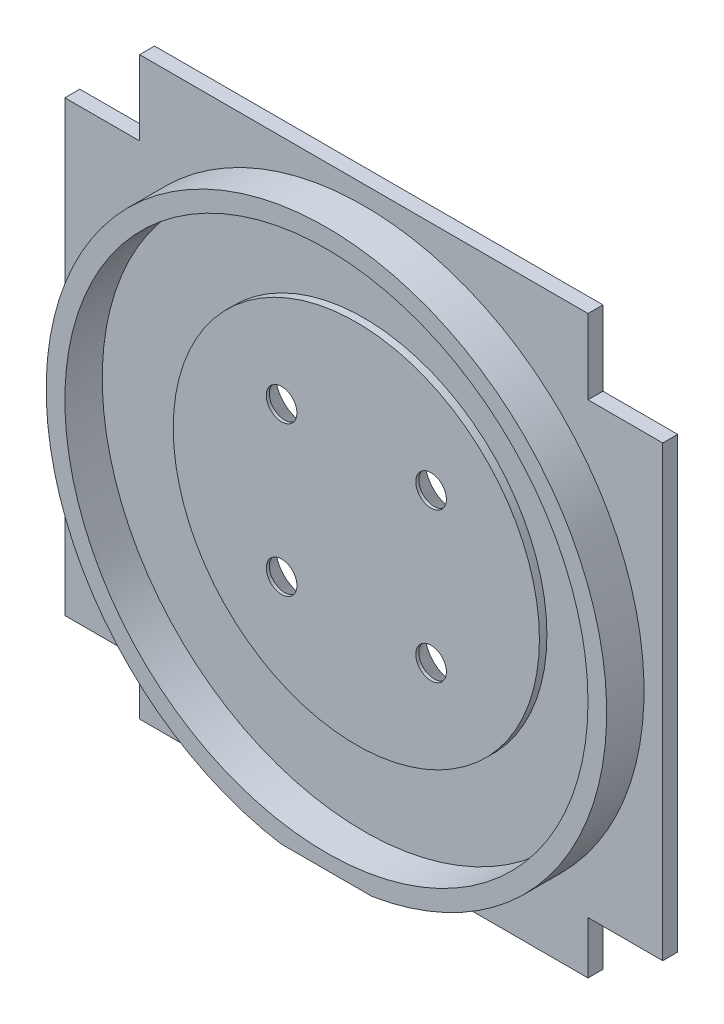
from build123d import *

# Parameters (mm, degrees)
ESQUISSE1_W             = 80
ESQUISSE1_H             = 80
BOSS_EXTRU_1_DEPTH      = 2
ESQUISSE2_R             = 24.5
BOSS_EXTRU_2_DEPTH      = 1
ESQUISSE3_R             = 2.05
ENL_V_MAT_EXTRU_1_DEPTH = 4
CHANFREIN1_SIZE         = 1.75
CHANFREIN1_SIZE2        = 2.594481695
ESQUISSE4_R             = 37.5
ESQUISSE4_R_2           = 35
BOSS_EXTRU_3_DEPTH      = 5
ESQUISSE5_W             = 80
ESQUISSE5_H             = 3
ENL_V_MAT_EXTRU_2_DEPTH = 8
ESQUISSE6_W             = 10
ESQUISSE6_H             = 10
ESQUISSE6_H_2           = 7
ENL_V_MAT_EXTRU_3_DEPTH = 8


with BuildPart() as part:
    # Esquisse1 → Boss.-Extru.1 (new body)
    with BuildSketch(Plane.XY):
        with Locations((40, 40)):
            Rectangle(ESQUISSE1_W, ESQUISSE1_H)
    extrude(amount=BOSS_EXTRU_1_DEPTH)

    # Esquisse2 → Boss.-Extru.2 (add)
    with BuildSketch(Plane.XY.offset(2)):
        with Locations((40, 40)):
            Circle(ESQUISSE2_R)
    extrude(amount=BOSS_EXTRU_2_DEPTH)

    # Esquisse3 → Enlèv. mat.-Extru.1 (cut, through all)
    with BuildSketch(Plane(origin=(0, 0, 0), x_dir=(-1, 0, 0), z_dir=(0, 0, -1))):
        with Locations((-50, 50)):
            Circle(ESQUISSE3_R)
        with Locations((-50, 30)):
            Circle(ESQUISSE3_R)
        with Locations((-30, 30)):
            Circle(ESQUISSE3_R)
        with Locations((-30, 50)):
            Circle(ESQUISSE3_R)
    extrude(amount=-ENL_V_MAT_EXTRU_1_DEPTH, mode=Mode.SUBTRACT)

    # Chanfrein1
    chanfrein1_edges = [part.edges().sort_by_distance(p)[0] for p in [
        (52.05, 50, 0),
        (52.05, 30, 0),
        (32.05, 30, 0),
        (32.05, 50, 0),
    ]]
    chanfrein1_side = [part.faces().sort_by_distance(p)[0] for p in [
        (40, 40, 0),
    ]]
    chamfer(chanfrein1_edges, length=CHANFREIN1_SIZE, length2=CHANFREIN1_SIZE2, reference=chanfrein1_side[0])

    # Esquisse4 → Boss.-Extru.3 (add)
    with BuildSketch(Plane.XY.offset(2)):
        with Locations((40, 40)):
            Circle(ESQUISSE4_R)
        with Locations((40, 40)):
            Circle(ESQUISSE4_R_2, mode=Mode.SUBTRACT)
    extrude(amount=BOSS_EXTRU_3_DEPTH)

    # Esquisse5 → Enlèv. mat.-Extru.2 (cut, through all)
    with BuildSketch(Plane(origin=(0, 0, 0), x_dir=(-1, 0, 0), z_dir=(0, 0, -1))):
        with Locations((-40, 1.5)):
            Rectangle(ESQUISSE5_W, ESQUISSE5_H)
    extrude(amount=-ENL_V_MAT_EXTRU_2_DEPTH, mode=Mode.SUBTRACT)

    # Esquisse6 → Enlèv. mat.-Extru.3 (cut, through all)
    with BuildSketch(Plane(origin=(0, 0, 0), x_dir=(-1, 0, 0), z_dir=(0, 0, -1))):
        with Locations((-75, 75)):
            Rectangle(ESQUISSE6_W, ESQUISSE6_H)
        with Locations((-5, 75)):
            Rectangle(ESQUISSE6_W, ESQUISSE6_H)
        with Locations((-5, 6.5)):
            Rectangle(ESQUISSE6_W, ESQUISSE6_H_2)
        with Locations((-75, 6.5)):
            Rectangle(ESQUISSE6_W, ESQUISSE6_H_2)
    extrude(amount=-ENL_V_MAT_EXTRU_3_DEPTH, mode=Mode.SUBTRACT)


solid = part.part
